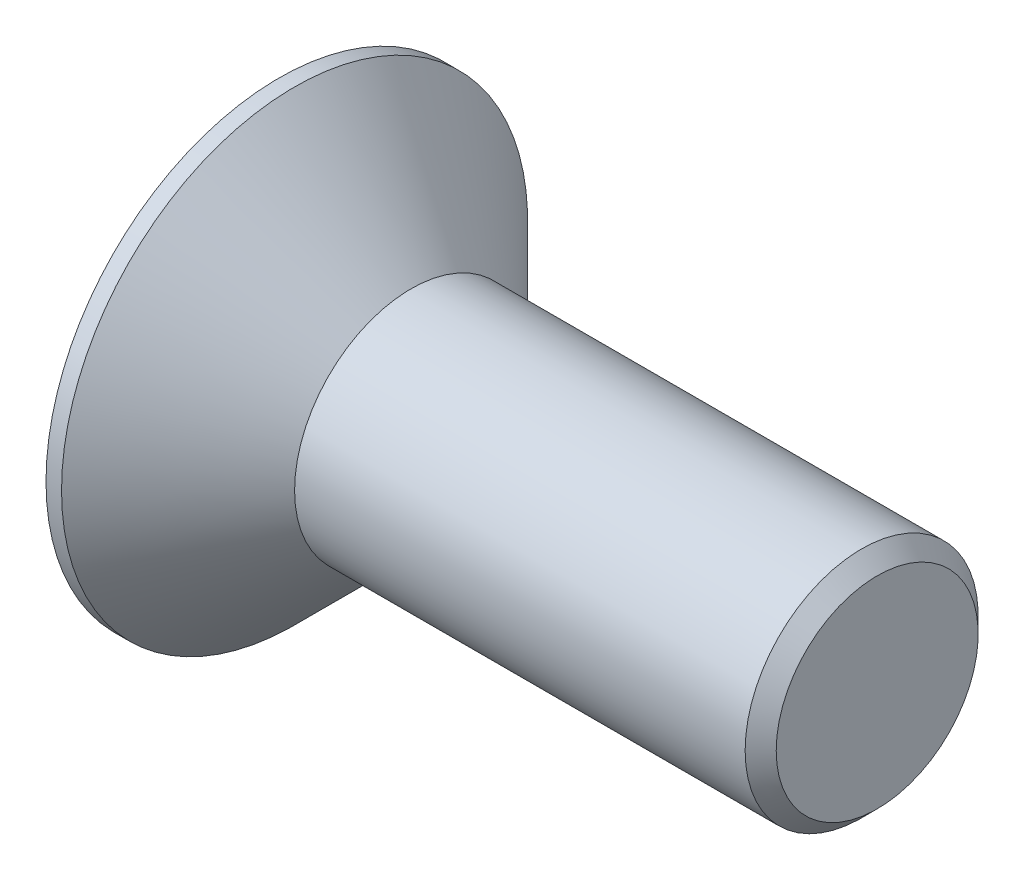
from build123d import *

# Parameters (mm, degrees)
ENL_V_MAT_EXTRU_1_DEPTH = 2
CHANFREIN1_SIZE         = 0.2


with BuildPart() as part:
    # Esquisse1 → Révolution1 (revolve)
    with BuildSketch(Plane.XY):
        Polygon((0, 0), (0, 3), (0.2, 3), (1.7, 1.5), (7.7, 1.5), (7.7, 0), align=None)
    revolve(axis=Axis((0, 0, 0), (1, 0, 0)))

    # Esquisse2 → Enlèv. mat.-Extru.1 (cut)
    with BuildSketch(Plane.ZY):
        Polygon((0.433012702, -0.75), (0.866025404, 0), (0.433012702, 0.75), (-0.433012702, 0.75), (-0.866025404, 0), (-0.433012702, -0.75), align=None)
    extrude(amount=-ENL_V_MAT_EXTRU_1_DEPTH, mode=Mode.SUBTRACT)

    # Chanfrein1
    chanfrein1_edges = [part.edges().sort_by_distance(p)[0] for p in [
        (7.7, -1.5, 0),
    ]]
    chamfer(chanfrein1_edges, length=CHANFREIN1_SIZE)


solid = part.part
